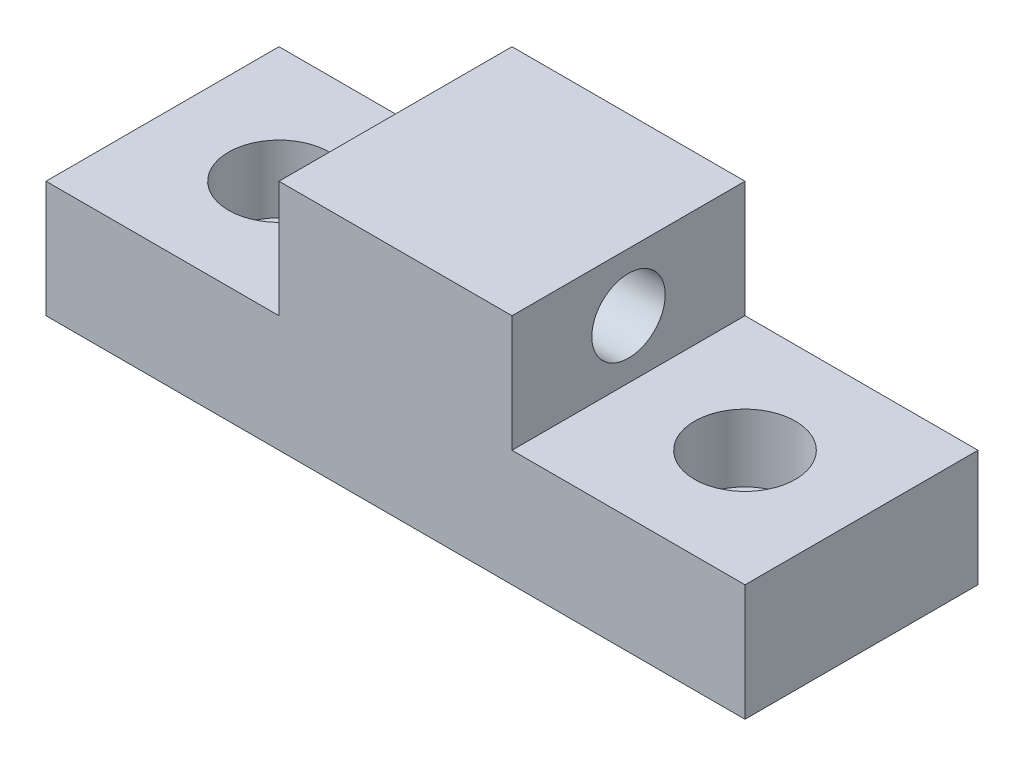
from build123d import *

# Parameters (mm, degrees)
SKETCH1_W           = 76.2
SKETCH1_H           = 25.4
SKETCH1_R           = 3.501199875
BOSS_EXTRUDE1_DEPTH = 12.7
SKETCH2_W           = 25.4
SKETCH2_H           = 25.4
BOSS_EXTRUDE2_DEPTH = 12.7
SKETCH3_R           = 4.001199875
CUT_EXTRUDE1_DEPTH  = 43.7
SKETCH4_R           = 5.5
CUT_EXTRUDE2_DEPTH  = 7.35


with BuildPart() as part:
    # Sketch1 → Boss-Extrude1 (new body)
    with BuildSketch(Plane(origin=(0, 0, 0), x_dir=(1, 0, 0), z_dir=(0, 1, 0))):
        Rectangle(SKETCH1_W, SKETCH1_H)
        with Locations((-25.4, 0)):
            Circle(SKETCH1_R, mode=Mode.SUBTRACT)
        with Locations((25.4, 0)):
            Circle(SKETCH1_R, mode=Mode.SUBTRACT)
    extrude(amount=BOSS_EXTRUDE1_DEPTH)

    # Sketch2 → Boss-Extrude2 (add)
    with BuildSketch(Plane(origin=(0, 12.7, 0), x_dir=(1, 0, 0), z_dir=(0, 1, 0))):
        Rectangle(SKETCH2_W, SKETCH2_H)
    extrude(amount=BOSS_EXTRUDE2_DEPTH)

    # Sketch3 → Cut-Extrude1 (cut)
    with BuildSketch(Plane.ZY.offset(12.7)):
        with Locations((0, 19.05)):
            Circle(SKETCH3_R)
    extrude(amount=-CUT_EXTRUDE1_DEPTH, mode=Mode.SUBTRACT)

    # Sketch4 → Cut-Extrude2 (cut)
    with BuildSketch(Plane(origin=(0, 12.7, 0), x_dir=(1, 0, 0), z_dir=(0, 1, 0))):
        with Locations((-25.4, 0)):
            Circle(SKETCH4_R)
        with Locations((25.4, 0)):
            Circle(SKETCH4_R)
    extrude(amount=-CUT_EXTRUDE2_DEPTH, mode=Mode.SUBTRACT)


solid = part.part
